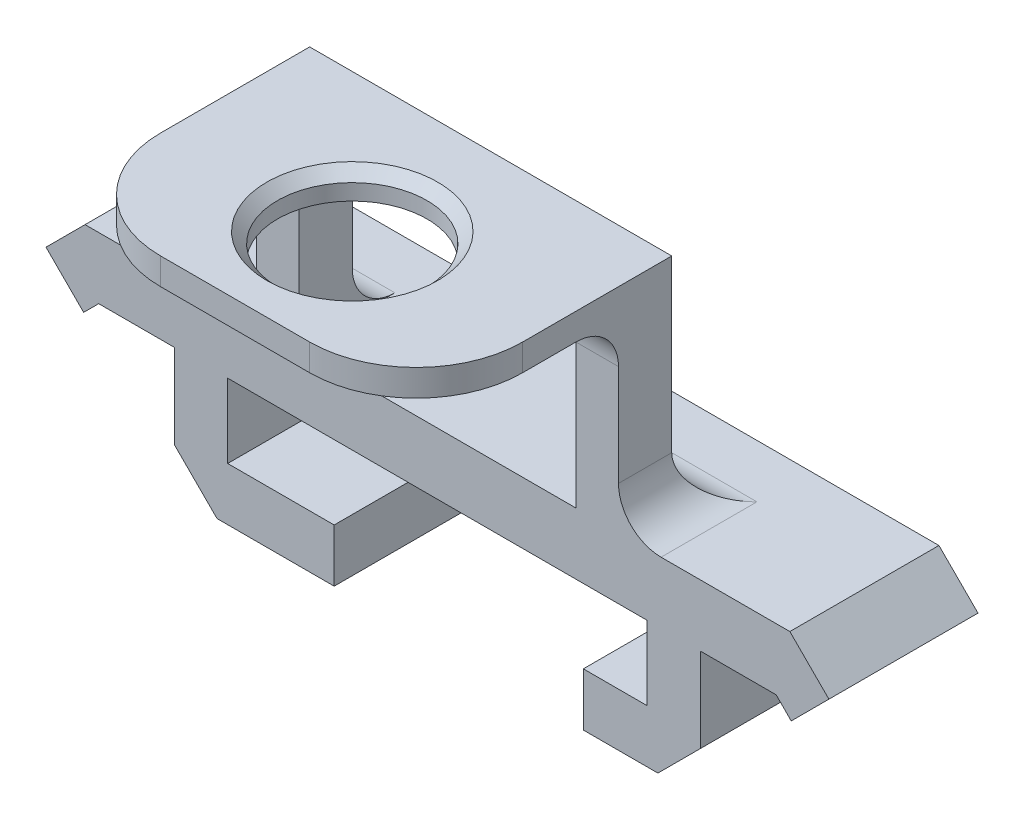
from build123d import *

# Parameters (mm, degrees)
BOSS_EXTRUDE2_DEPTH = 5
BOSS_EXTRUDE3_DEPTH = 2
SKETCH8_W           = 2.5
SKETCH8_H           = 7
BOSS_EXTRUDE4_DEPTH = 5.96
SKETCH10_W          = 7
SKETCH10_H          = 2.49
BOSS_EXTRUDE5_DEPTH = 3
SKETCH11_W          = 7
SKETCH11_H          = 2.49
BOSS_EXTRUDE6_DEPTH = 5
SKETCH12_W          = 17
SKETCH12_H          = 2.5
BOSS_EXTRUDE7_DEPTH = 10
CUT_EXTRUDE7_REACH  = 39.855
SKETCH14_W          = 13
SKETCH14_H          = 8.75
SKETCH16_W          = 17
SKETCH16_H          = 1.25
BOSS_EXTRUDE8_DEPTH = 9.5
CUT_EXTRUDE8_REACH  = 32.06
SKETCH17_R          = 3.51
FILLET7_R           = 2
FILLET8_R           = 5
FILLET9_R           = 5
CHAMFER1_SIZE       = 2
CHAMFER2_SIZE       = 2
FILLET11_R          = 2
FILLET12_R          = 2
FILLET13_R          = 2
FILLET14_R          = 2
FILLET16_R          = 2
CHAMFER3_SIZE       = 0.5


with BuildPart() as part:
    # Sketch2 → Boss-Extrude2 (new body)
    with BuildSketch(Plane.XY):
        Polygon((15.905331571, 19.450007488), (-15.905331571, 19.450007488), (-16.612438353, 18.742900707), (-18.380205305, 20.51066766), (-16.54629868, 22.344574285), (16.54629868, 22.344574285), (18.3802029, 20.510670065), (16.610591633, 18.741058798), align=None)
    extrude(amount=BOSS_EXTRUDE2_DEPTH)

    # Sketch2_2 → Boss-Extrude3 (add)
    with BuildSketch(Plane.XY):
        Polygon((15.905331571, 19.450007488), (-15.905331571, 19.450007488), (-16.612438353, 18.742900707), (-18.380205305, 20.51066766), (-16.54629868, 22.344574285), (16.54629868, 22.344574285), (18.3802029, 20.510670065), (16.610591633, 18.741058798), align=None)
    extrude(amount=-BOSS_EXTRUDE3_DEPTH)

    # Sketch8 → Boss-Extrude4 (add)
    with BuildSketch(Plane(origin=(0, 19.450007488, 0), x_dir=(-1, 0, 0), z_dir=(0, -1, 0))):
        with Locations((11.1, -1.5)):
            Rectangle(SKETCH8_W, SKETCH8_H)
        with Locations((-11.1, -1.5)):
            Rectangle(SKETCH8_W, SKETCH8_H)
    extrude(amount=BOSS_EXTRUDE4_DEPTH)

    # Sketch10 → Boss-Extrude5 (add)
    with BuildSketch(Plane.ZY.offset(-9.85)):
        with Locations((1.5, 14.735007488)):
            Rectangle(SKETCH10_W, SKETCH10_H)
    extrude(amount=BOSS_EXTRUDE5_DEPTH)

    # Sketch11 → Boss-Extrude6 (add)
    with BuildSketch(Plane(origin=(-9.85, 0, 0), x_dir=(0, 0, -1), z_dir=(1, 0, 0))):
        with Locations((-1.5, 14.735007488)):
            Rectangle(SKETCH11_W, SKETCH11_H)
    extrude(amount=BOSS_EXTRUDE6_DEPTH)

    # Sketch12 → Boss-Extrude7 (add)
    with BuildSketch(Plane(origin=(0, 22.344574285, 0), x_dir=(1, 0, 0), z_dir=(0, 1, 0))):
        with Locations((0, -3.75)):
            Rectangle(SKETCH12_W, SKETCH12_H)
    extrude(amount=BOSS_EXTRUDE7_DEPTH)

    # Sketch14 → Cut-Extrude7 (cut, up to next)
    with BuildSketch(Plane.XY.offset(5), mode=Mode.PRIVATE) as cut_extrude7_sk1:
        with Locations((0, 26.719574285)):
            Rectangle(SKETCH14_W, SKETCH14_H)
    cut_extrude7_tool1 = extrude(cut_extrude7_sk1.sketch, amount=-CUT_EXTRUDE7_REACH, mode=Mode.PRIVATE) & part.part
    add(cut_extrude7_tool1.solids().sort_by_distance((0, 26.719574, 5))[0], mode=Mode.SUBTRACT)

    # Sketch16 → Boss-Extrude8 (add)
    with BuildSketch(Plane.XY.offset(5)):
        with Locations((0, 31.719574285)):
            Rectangle(SKETCH16_W, SKETCH16_H)
    extrude(amount=BOSS_EXTRUDE8_DEPTH)

    # Sketch17 → Cut-Extrude8 (cut, up to next)
    with BuildSketch(Plane(origin=(0, 32.344574285, 0), x_dir=(1, 0, 0), z_dir=(0, 1, 0)), mode=Mode.PRIVATE) as cut_extrude8_sk1:
        with Locations((0, -9)):
            Circle(SKETCH17_R)
    cut_extrude8_tool1 = extrude(cut_extrude8_sk1.sketch, amount=-CUT_EXTRUDE8_REACH, mode=Mode.PRIVATE) & part.part
    add(cut_extrude8_tool1.solids().sort_by_distance((0, 32.344574, 9))[0], mode=Mode.SUBTRACT)

    # Fillet7
    fillet7_edges = [part.edges().sort_by_distance(p)[0] for p in [
        (7.5, 31.094574285, 5),
    ]]
    fillet(fillet7_edges, radius=FILLET7_R)

    # Fillet8
    fillet8_edges = [part.edges().sort_by_distance(p)[0] for p in [
        (8.5, 31.719574285, 14.5),
    ]]
    fillet(fillet8_edges, radius=FILLET8_R)

    # Fillet9
    fillet9_edges = [part.edges().sort_by_distance(p)[0] for p in [
        (-8.5, 31.719574285, 14.5),
    ]]
    fillet(fillet9_edges, radius=FILLET9_R)

    # Chamfer1
    chamfer1_edges = [part.edges().sort_by_distance(p)[0] for p in [
        (-12.35, 13.490007488, 1.5),
    ]]
    chamfer(chamfer1_edges, length=CHAMFER1_SIZE)

    # Chamfer2
    chamfer2_edges = [part.edges().sort_by_distance(p)[0] for p in [
        (12.35, 13.490007488, 1.5),
    ]]
    chamfer(chamfer2_edges, length=CHAMFER2_SIZE)

    # Fillet11
    fillet11_edges = [part.edges().sort_by_distance(p)[0] for p in [
        (-8.5, 22.344574285, 3.75),
    ]]
    fillet(fillet11_edges, radius=FILLET11_R)

    # Fillet12
    fillet12_edges = [part.edges().sort_by_distance(p)[0] for p in [
        (8.5, 22.344574285, 3.75),
    ]]
    fillet(fillet12_edges, radius=FILLET12_R)

    # Fillet13
    fillet13_edges = [part.edges().sort_by_distance(p)[0] for p in [
        (8.5, 22.344574285, 2.5),
    ]]
    fillet(fillet13_edges, radius=FILLET13_R)

    # Fillet14
    fillet14_edges = [part.edges().sort_by_distance(p)[0] for p in [
        (-8.5, 22.344574285, 2.5),
    ]]
    fillet(fillet14_edges, radius=FILLET14_R)

    # Fillet16
    fillet16_edges = [part.edges().sort_by_distance(p)[0] for p in [
        (-7.5, 31.094574285, 5),
    ]]
    fillet(fillet16_edges, radius=FILLET16_R)

    # Chamfer3
    chamfer3_edges = [part.edges().sort_by_distance(p)[0] for p in [
        (-3.51, 32.344574285, 9),
    ]]
    chamfer(chamfer3_edges, length=CHAMFER3_SIZE)


solid = part.part
